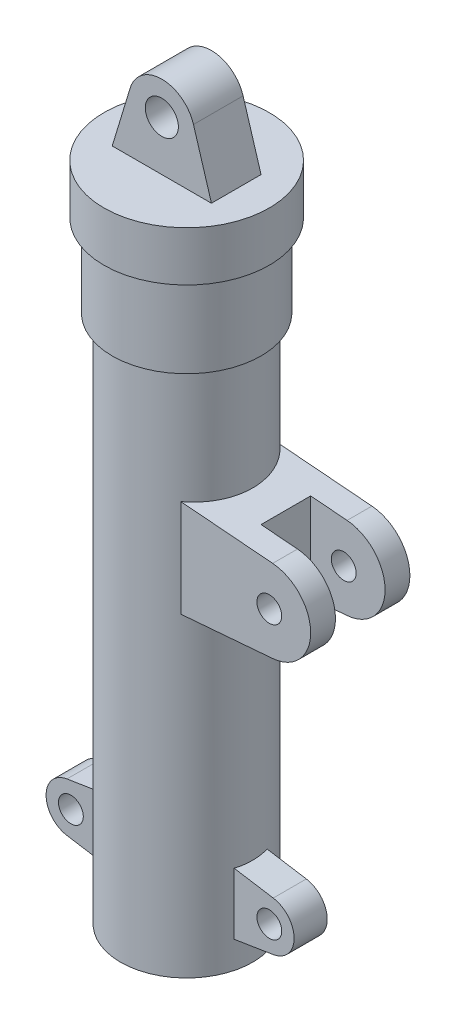
from build123d import *

# Parameters (mm, degrees)
SKETCH2_R           = 10
BOSS_EXTRUDE1_DEPTH = 15
SKETCH3_R           = 7.5
BOSS_EXTRUDE2_DEPTH = 10
SKETCH8_R           = 7.5
BOSS_EXTRUDE3_DEPTH = 30
SKETCH4_W           = 35
SKETCH4_H           = 315
SKETCH9_W           = 70
SKETCH9_H           = 80
CUT_EXTRUDE1_DEPTH  = 15


with BuildPart() as part:
    # Sketch1 → Base-Revolve (revolve)
    with BuildSketch(Plane.XY):
        Polygon((22.5, -330), (40, -330), (40, -10), (45, -10), (45, 40), (50, 40), (50, 70), (0, 70), (0, 55), (35, 55), (35, -325), (22.5, -325), align=None)
    revolve(axis=Axis((0, 100, 0), (0, -1, 0)))

    # Sketch2 → Boss-Extrude1 (add, symmetric)
    with BuildSketch(Plane.XY):
        with BuildLine():
            Line((19.138857956, 105.805524623), (30, 70))
            Line((30, 70), (-30, 70))
            Line((-30, 70), (-19.138857956, 105.805524623))
            ThreePointArc((-19.138857956, 105.805524623), (0, 120), (19.138857956, 105.805524623))
        make_face()
        with Locations((0, 100)):
            Circle(SKETCH2_R, mode=Mode.SUBTRACT)
    extrude(amount=BOSS_EXTRUDE1_DEPTH, both=True)

    # Sketch3 → Boss-Extrude2 (add, symmetric)
    with BuildSketch(Plane.XY):
        with BuildLine():
            Line((62.373967528, -280.189048708), (30, -275))
            Line((30, -275), (30, -315))
            Line((30, -315), (62.373967528, -309.810951292))
            ThreePointArc((62.373967528, -309.810951292), (75, -295), (62.373967528, -280.189048708))
        make_face()
        with Locations((60, -295)):
            Circle(SKETCH3_R, mode=Mode.SUBTRACT)
    boss_extrude2 = extrude(amount=BOSS_EXTRUDE2_DEPTH, both=True)

    # Mirror1: Boss-Extrude2 across plane
    add(boss_extrude2.mirror(Plane(origin=(0, 0, 0), x_dir=(0, 0, 1), z_dir=(1, 0, 0))))

    # Sketch8 → Boss-Extrude3 (add, symmetric)
    with BuildSketch(Plane.XY):
        with BuildLine():
            Line((82.041582998, -85.08350067), (20, -80))
            Line((20, -80), (20, -140))
            Line((20, -140), (82.041582998, -134.91649933))
            ThreePointArc((82.041582998, -134.91649933), (105, -110), (82.041582998, -85.08350067))
        make_face()
        with Locations((80, -110)):
            Circle(SKETCH8_R, mode=Mode.SUBTRACT)
    extrude(amount=BOSS_EXTRUDE3_DEPTH, both=True)

    # Sketch4 → Cut-Revolve1 (revolve, cut)
    with BuildSketch(Plane.XY):
        with Locations((17.5, -167.5)):
            Rectangle(SKETCH4_W, SKETCH4_H)
    revolve(axis=Axis((0, 0, 0), (0, -1, 0)), mode=Mode.SUBTRACT)

    # Sketch9 → Cut-Extrude1 (cut, symmetric)
    with BuildSketch(Plane.XY):
        with Locations((95, -110)):
            Rectangle(SKETCH9_W, SKETCH9_H)
    extrude(amount=CUT_EXTRUDE1_DEPTH, both=True, mode=Mode.SUBTRACT)


solid = part.part
